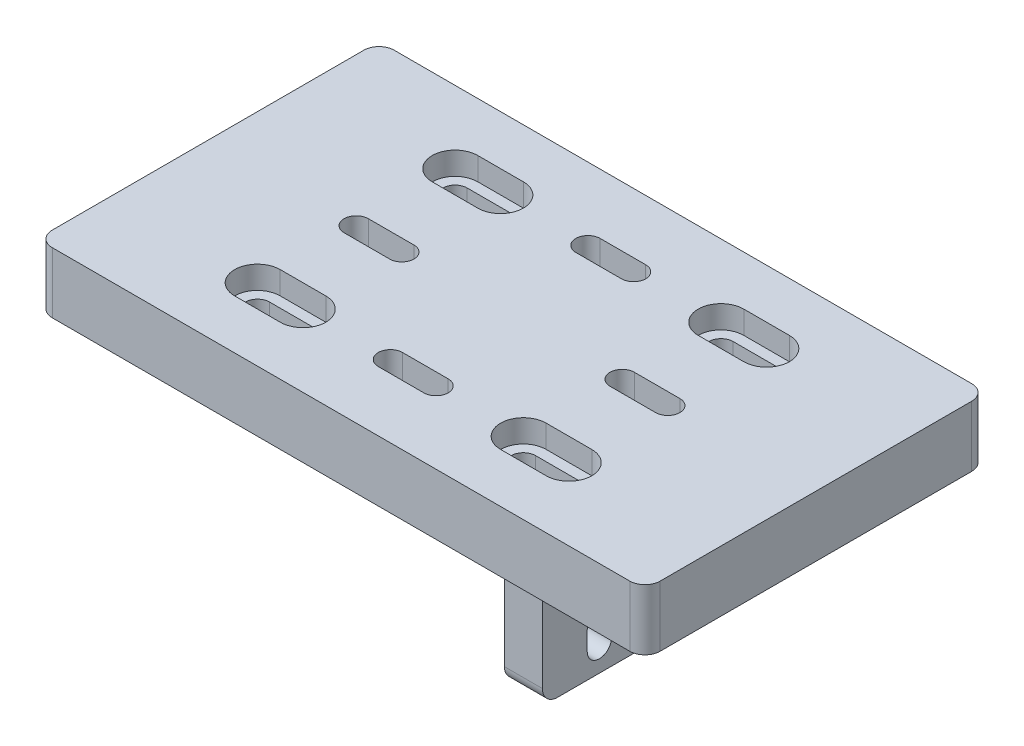
from build123d import *

# Parameters (mm, degrees)
CROQUIS2_W              = 80
CROQUIS2_H              = 45
SALIENTE_EXTRUIR1_DEPTH = 8
CORTAR_EXTRUIR1_DEPTH   = 3
CROQUIS4_W              = 5
CROQUIS4_H              = 15
SALIENTE_EXTRUIR2_DEPTH = 35
CORTAR_EXTRUIR2_DEPTH   = 34.5
REDONDEO1_R             = 5
CROQUIS6_W              = 10
CROQUIS6_H              = 5.6
CORTAR_EXTRUIR3_DEPTH   = 3
CROQUIS8_W              = 15
CROQUIS8_H              = 8
CORTAR_EXTRUIR4_DEPTH   = 34.5
REDONDEO2_R             = 2


with BuildPart() as part:
    # Croquis2 → Saliente-Extruir1 (new body)
    with BuildSketch(Plane(origin=(0, 0, 0), x_dir=(1, 0, 0), z_dir=(0, 1, 0))):
        Rectangle(CROQUIS2_W, CROQUIS2_H)
        with BuildLine():
            Line((-20.5, 14.6), (-14.5, 14.6))
            ThreePointArc((-14.5, 14.6), (-12.9, 13), (-14.5, 11.4))
            Line((-14.5, 11.4), (-20.5, 11.4))
            ThreePointArc((-20.5, 11.4), (-22.1, 13), (-20.5, 14.6))
        make_face(mode=Mode.SUBTRACT)
        with BuildLine():
            Line((20.5, 14.6), (14.5, 14.6))
            ThreePointArc((14.5, 14.6), (12.9, 13), (14.5, 11.4))
            Line((14.5, 11.4), (20.5, 11.4))
            ThreePointArc((20.5, 11.4), (22.1, 13), (20.5, 14.6))
        make_face(mode=Mode.SUBTRACT)
        with BuildLine():
            Line((20.5, -14.6), (14.5, -14.6))
            ThreePointArc((14.5, -14.6), (12.9, -13), (14.5, -11.4))
            Line((14.5, -11.4), (20.5, -11.4))
            ThreePointArc((20.5, -11.4), (22.1, -13), (20.5, -14.6))
        make_face(mode=Mode.SUBTRACT)
        with BuildLine():
            Line((-20.5, -14.6), (-14.5, -14.6))
            ThreePointArc((-14.5, -14.6), (-12.9, -13), (-14.5, -11.4))
            Line((-14.5, -11.4), (-20.5, -11.4))
            ThreePointArc((-20.5, -11.4), (-22.1, -13), (-20.5, -14.6))
        make_face(mode=Mode.SUBTRACT)
        with BuildLine():
            Line((-20.5, 1.6), (-14.5, 1.6))
            ThreePointArc((-14.5, 1.6), (-12.9, 0), (-14.5, -1.6))
            Line((-14.5, -1.6), (-20.5, -1.6))
            ThreePointArc((-20.5, -1.6), (-22.1, 0), (-20.5, 1.6))
        make_face(mode=Mode.SUBTRACT)
        with BuildLine():
            Line((20.5, 1.6), (14.5, 1.6))
            ThreePointArc((14.5, 1.6), (12.9, 0), (14.5, -1.6))
            Line((14.5, -1.6), (20.5, -1.6))
            ThreePointArc((20.5, -1.6), (22.1, 0), (20.5, 1.6))
        make_face(mode=Mode.SUBTRACT)
        with BuildLine():
            Line((-3, 14.6), (3, 14.6))
            ThreePointArc((3, 14.6), (4.6, 13), (3, 11.4))
            Line((3, 11.4), (-3, 11.4))
            ThreePointArc((-3, 11.4), (-4.6, 13), (-3, 14.6))
        make_face(mode=Mode.SUBTRACT)
        with BuildLine():
            Line((-3, -11.4), (3, -11.4))
            ThreePointArc((3, -11.4), (4.6, -13), (3, -14.6))
            Line((3, -14.6), (-3, -14.6))
            ThreePointArc((-3, -14.6), (-4.6, -13), (-3, -11.4))
        make_face(mode=Mode.SUBTRACT)
    extrude(amount=SALIENTE_EXTRUIR1_DEPTH)

    # Croquis3 → Cortar-Extruir1 (cut)
    with BuildSketch(Plane(origin=(0, 8, 0), x_dir=(1, 0, 0), z_dir=(0, 1, 0))):
        with BuildLine():
            Line((-20.5, 16), (-14.5, 16))
            ThreePointArc((-14.5, 16), (-11.5, 13), (-14.5, 10))
            Line((-14.5, 10), (-20.5, 10))
            ThreePointArc((-20.5, 10), (-23.5, 13), (-20.5, 16))
        make_face()
        with BuildLine():
            Line((20.5, 16), (14.5, 16))
            ThreePointArc((14.5, 16), (11.5, 13), (14.5, 10))
            Line((14.5, 10), (20.5, 10))
            ThreePointArc((20.5, 10), (23.5, 13), (20.5, 16))
        make_face()
        with BuildLine():
            Line((20.5, -16), (14.5, -16))
            ThreePointArc((14.5, -16), (11.5, -13), (14.5, -10))
            Line((14.5, -10), (20.5, -10))
            ThreePointArc((20.5, -10), (23.5, -13), (20.5, -16))
        make_face()
        with BuildLine():
            Line((-20.5, -16), (-14.5, -16))
            ThreePointArc((-14.5, -16), (-11.5, -13), (-14.5, -10))
            Line((-14.5, -10), (-20.5, -10))
            ThreePointArc((-20.5, -10), (-23.5, -13), (-20.5, -16))
        make_face()
    extrude(amount=-CORTAR_EXTRUIR1_DEPTH, mode=Mode.SUBTRACT)

    # Croquis4 → Saliente-Extruir2 (add)
    with BuildSketch(Plane.XZ):
        with Locations((9, 0)):
            Rectangle(CROQUIS4_W, CROQUIS4_H)
    extrude(amount=SALIENTE_EXTRUIR2_DEPTH)

    # Croquis5 → Cortar-Extruir2 (cut, through all)
    with BuildSketch(Plane.ZY.offset(-6.5)):
        with BuildLine():
            Line((1.6, -11.25), (1.6, -13.75))
            ThreePointArc((1.6, -13.75), (0, -15.35), (-1.6, -13.75))
            Line((-1.6, -13.75), (-1.6, -11.25))
            ThreePointArc((-1.6, -11.25), (0, -9.65), (1.6, -11.25))
        make_face()
        with BuildLine():
            Line((1.6, -23.75), (1.6, -21.25))
            ThreePointArc((1.6, -21.25), (0, -19.65), (-1.6, -21.25))
            Line((-1.6, -21.25), (-1.6, -23.75))
            ThreePointArc((-1.6, -23.75), (0, -25.35), (1.6, -23.75))
        make_face()
    extrude(amount=-CORTAR_EXTRUIR2_DEPTH, mode=Mode.SUBTRACT)

    # Redondeo1
    redondeo1_edges = [part.edges().sort_by_distance(p)[0] for p in [
        (9, 0, 7.5),
        (9, 0, -7.5),
    ]]
    fillet(redondeo1_edges, radius=REDONDEO1_R)

    # Croquis6 → Cortar-Extruir3 (cut)
    with BuildSketch(Plane.XZ):
        with Locations((-17.5, 0)):
            Rectangle(CROQUIS6_W, CROQUIS6_H)
        with Locations((17.5, 0)):
            Rectangle(CROQUIS6_W, CROQUIS6_H)
        with Locations((0, 13)):
            Rectangle(CROQUIS6_W, CROQUIS6_H)
        with Locations((0, -13)):
            Rectangle(CROQUIS6_W, CROQUIS6_H)
    extrude(amount=-CORTAR_EXTRUIR3_DEPTH, mode=Mode.SUBTRACT)

    # Croquis8 → Cortar-Extruir4 (cut, through all)
    with BuildSketch(Plane.ZY.offset(-6.5)):
        with Locations((0, -31)):
            Rectangle(CROQUIS8_W, CROQUIS8_H)
    extrude(amount=-CORTAR_EXTRUIR4_DEPTH, mode=Mode.SUBTRACT)

    # Redondeo2
    redondeo2_edges = [part.edges().sort_by_distance(p)[0] for p in [
        (9, -27, -7.5),
        (9, -27, 7.5),
        (40, 4, 22.5),
        (-40, 4, 22.5),
        (-40, 4, -22.5),
        (40, 4, -22.5),
    ]]
    fillet(redondeo2_edges, radius=REDONDEO2_R)


solid = part.part
